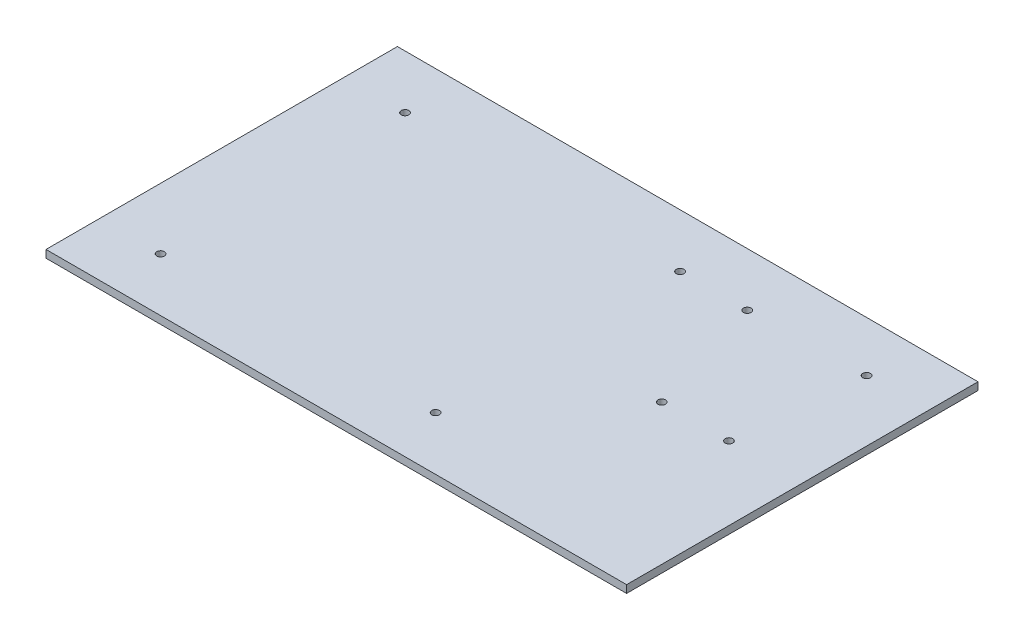
from build123d import *

# Parameters (mm, degrees)
SKETCH1_W           = 241.3
SKETCH1_H           = 146.05
SKETCH1_R           = 1.5875
BOSS_EXTRUDE1_DEPTH = 3.175


with BuildPart() as part:
    # Sketch1 → Boss-Extrude1 (new body)
    with BuildSketch(Plane(origin=(0, 0, 0), x_dir=(1, 0, 0), z_dir=(0, 1, 0))):
        Rectangle(SKETCH1_W, SKETCH1_H)
        with Locations((90.17, 0)):
            Circle(SKETCH1_R, mode=Mode.SUBTRACT)
        with Locations((62.23, 0)):
            Circle(SKETCH1_R, mode=Mode.SUBTRACT)
        with Locations((46.99, 50.8)):
            Circle(SKETCH1_R, mode=Mode.SUBTRACT)
        with Locations((95.27, 52.1)):
            Circle(SKETCH1_R, mode=Mode.SUBTRACT)
        with Locations((19.05, 50.8)):
            Circle(SKETCH1_R, mode=Mode.SUBTRACT)
        with Locations((19.05, -50.8)):
            Circle(SKETCH1_R, mode=Mode.SUBTRACT)
        with Locations((-95.25, -50.8)):
            Circle(SKETCH1_R, mode=Mode.SUBTRACT)
        with Locations((-95.25, 50.8)):
            Circle(SKETCH1_R, mode=Mode.SUBTRACT)
    extrude(amount=BOSS_EXTRUDE1_DEPTH)


solid = part.part
